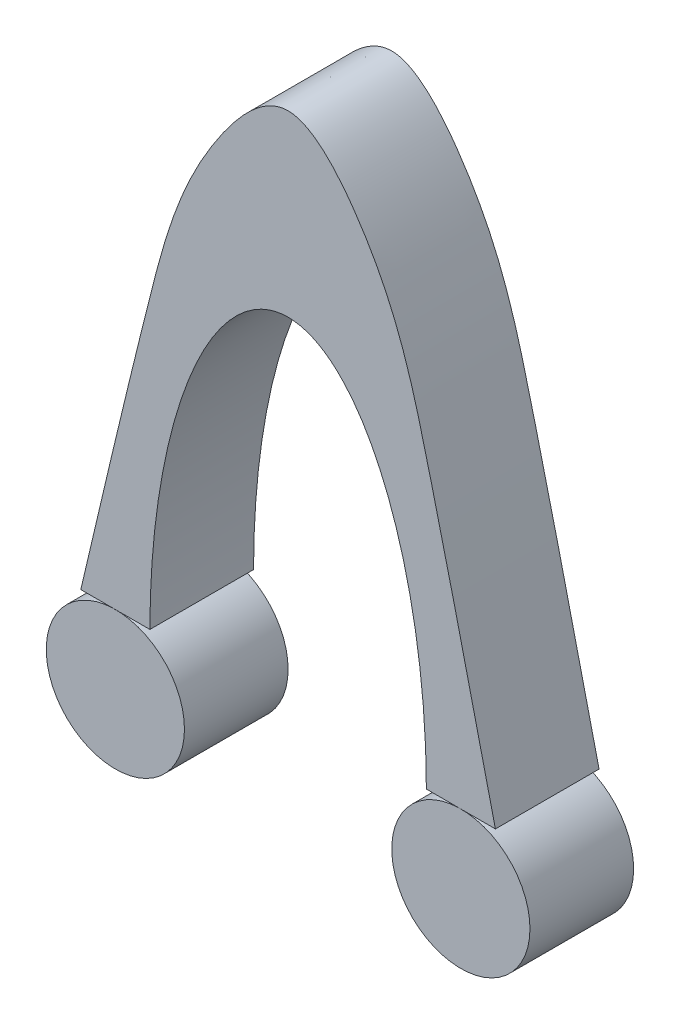
from build123d import *

# Parameters (mm, degrees)
EXTRUDE1_DEPTH   = 15
SKETCH2_R        = 20
EXTRUDE2_DEPTH   = 15
EXTRUDE2_2_DEPTH = 15


with BuildPart() as part:
    # Sketch1 → Extrude1 (new body, symmetric)
    with BuildSketch(Plane.XY):
        with BuildLine():
            Line((-60, 0), (-40, 0))
            add(Edge.make_bspline(
                [(40, 0), (40, 98.270762982), (0, 98.270762982), (-40, 98.270762982), (-40, 0)],
                knots=[4.71238898, 4.71238898, 4.71238898, 6.283185307, 6.283185307, 7.853981634, 7.853981634, 7.853981634], degree=2, weights=[1, 0.707106781, 1, 0.707106781, 1]))
            Line((40, 0), (60, 0))
            add(Edge.make_bspline(
                [(-60, 0), (-53.373340512, 28.302440828), (-42.58264787, 74.389453533), (-29.401263804, 124.122067435), (0, 158.433417031), (29.401263804, 124.122067435), (42.58264787, 74.389453533), (53.373340512, 28.302440828), (60, 0)],
                knots=[0, 0, 0, 0, 0.25877782, 0.421387567, 0.5, 0.578612433, 0.74122218, 1, 1, 1, 1], degree=3))
        make_face()
    extrude(amount=EXTRUDE1_DEPTH, both=True)


with BuildPart() as body_2:
    # Sketch2 → Extrude2 (new body, symmetric)
    with BuildSketch(Plane.XY):
        with Locations((50, -20)):
            Circle(SKETCH2_R)
    extrude(amount=EXTRUDE2_DEPTH, both=True)


with BuildPart() as body_3:
    # Sketch2 → Extrude2 2 (new body, symmetric)
    with BuildSketch(Plane.XY):
        with Locations((-50, -20)):
            Circle(SKETCH2_R)
    extrude(amount=EXTRUDE2_2_DEPTH, both=True)


solid = Compound([part.part, body_2.part, body_3.part])
